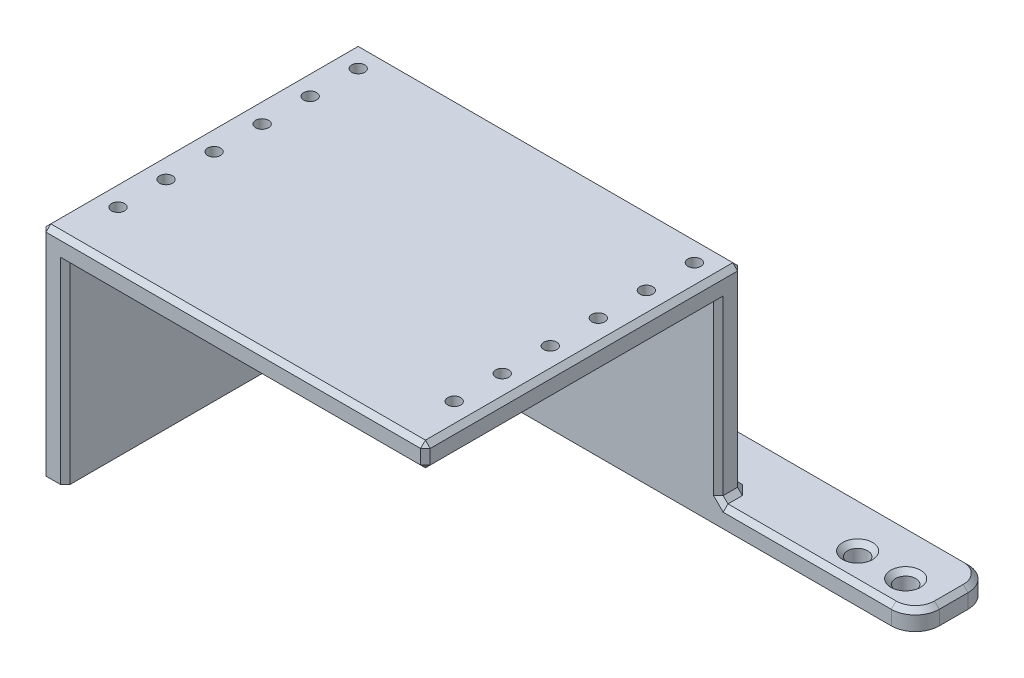
from build123d import *

# Parameters (mm, degrees)
SKETCH1_R           = 2.1
BOSS_EXTRUDE1_DEPTH = 4
SKETCH2_W           = 80
SKETCH2_H           = 5
BOSS_EXTRUDE2_DEPTH = 36
SKETCH3_W           = 5
SKETCH3_H           = 40
BOSS_EXTRUDE3_DEPTH = 61
SKETCH4_W           = 80
SKETCH4_H           = 66
BOSS_EXTRUDE4_DEPTH = 5
CHAMFER2_SIZE       = 1
SKETCH5_R           = 1.35
CUT_EXTRUDE1_DEPTH  = 5


with BuildPart() as part:
    # Sketch1 → Boss-Extrude1 (new body)
    with BuildSketch(Plane(origin=(0, 0, 0), x_dir=(1, 0, 0), z_dir=(0, 1, 0))):
        with BuildLine():
            Line((-58.8413396, 11.682242991), (52.1586604, 11.682242991))
            ThreePointArc((52.1586604, 11.682242991), (55.694194306, 10.217776897), (57.1586604, 6.682242991))
            Line((57.1586604, 6.682242991), (57.1586604, 0.682242991))
            ThreePointArc((57.1586604, 0.682242991), (55.694194306, -2.853290915), (52.1586604, -4.317757009))
            Line((52.1586604, -4.317757009), (-63.8413396, -4.317757009))
            Line((-63.8413396, -4.317757009), (-63.8413396, 6.682242991))
            ThreePointArc((-63.8413396, 6.682242991), (-62.376873506, 10.217776897), (-58.8413396, 11.682242991))
        make_face()
        with Locations((-58.8413396, 6.682242991)):
            Circle(SKETCH1_R, mode=Mode.SUBTRACT)
        with Locations((39.1586604, 1.682242991)):
            Circle(SKETCH1_R, mode=Mode.SUBTRACT)
        with Locations((49.1586604, 1.682242991)):
            Circle(SKETCH1_R, mode=Mode.SUBTRACT)
    extrude(amount=BOSS_EXTRUDE1_DEPTH)

    # Sketch2 → Boss-Extrude2 (add)
    with BuildSketch(Plane(origin=(0, 4, 0), x_dir=(1, 0, 0), z_dir=(0, 1, 0))):
        with Locations((-23.8413396, -1.817757009)):
            Rectangle(SKETCH2_W, SKETCH2_H)
    extrude(amount=BOSS_EXTRUDE2_DEPTH)

    # Sketch3 → Boss-Extrude3 (add)
    with BuildSketch(Plane.XY.offset(4.317757009)):
        with Locations((-61.3413396, 20)):
            Rectangle(SKETCH3_W, SKETCH3_H)
    extrude(amount=BOSS_EXTRUDE3_DEPTH)

    # Sketch4 → Boss-Extrude4 (add)
    with BuildSketch(Plane(origin=(0, 40, 0), x_dir=(1, 0, 0), z_dir=(0, 1, 0))):
        with Locations((-23.8413396, -32.317757009)):
            Rectangle(SKETCH4_W, SKETCH4_H)
    extrude(amount=BOSS_EXTRUDE4_DEPTH)

    # Chamfer2
    chamfer2_edges = [part.edges().sort_by_distance(p)[0] for p in [
        (55.694194306, 4, 2.853290915),
        (-60.9413396, 4, -6.682242991),
        (57.1586604, 4, -3.682242991),
        (37.0586604, 4, -1.682242991),
        (55.694194306, 4, -10.217776897),
        (47.0586604, 4, -1.682242991),
        (-3.3413396, 4, -11.682242991),
        (34.1586604, 4, 4.317757009),
        (-63.8413396, 24.5, -0.682242991),
        (16.1586604, 4, 1.817757009),
        (16.1586604, 22, 4.317757009),
        (-23.8413396, 4, -0.682242991),
        (16.1586604, 24.5, -0.682242991),
        (-62.376873506, 4, -10.217776897),
        (-63.8413396, 22.5, 65.317757009),
        (-58.8413396, 20, 65.317757009),
        (-21.3413396, 40, 65.317757009),
        (16.1586604, 40, 34.817757009),
        (16.1586604, 42.5, 65.317757009),
        (-63.8413396, 45, 32.317757009),
        (-23.8413396, 45, 65.317757009),
        (16.1586604, 45, 32.317757009),
        (-23.8413396, 45, -0.682242991),
        (-63.8413396, 4, -3.682242991),
    ]]
    chamfer(chamfer2_edges, length=CHAMFER2_SIZE)

    # Sketch5 → Cut-Extrude1 (cut)
    with BuildSketch(Plane(origin=(0, 45, 0), x_dir=(1, 0, 0), z_dir=(0, 1, 0))):
        with Locations((11.1586604, -4.317757009)):
            Circle(SKETCH5_R)
        with Locations((-58.8413396, -4.317757009)):
            Circle(SKETCH5_R)
        with Locations((-58.8413396, -14.317757009)):
            Circle(SKETCH5_R)
        with Locations((11.1586604, -14.317757009)):
            Circle(SKETCH5_R)
        with Locations((-58.8413396, -24.317757009)):
            Circle(SKETCH5_R)
        with Locations((11.1586604, -24.317757009)):
            Circle(SKETCH5_R)
        with Locations((-58.8413396, -34.317757009)):
            Circle(SKETCH5_R)
        with Locations((11.1586604, -34.317757009)):
            Circle(SKETCH5_R)
        with Locations((-58.8413396, -44.317757009)):
            Circle(SKETCH5_R)
        with Locations((11.1586604, -44.317757009)):
            Circle(SKETCH5_R)
        with Locations((-58.8413396, -54.317757009)):
            Circle(SKETCH5_R)
        with Locations((11.1586604, -54.317757009)):
            Circle(SKETCH5_R)
    extrude(amount=-CUT_EXTRUDE1_DEPTH, mode=Mode.SUBTRACT)


solid = part.part
